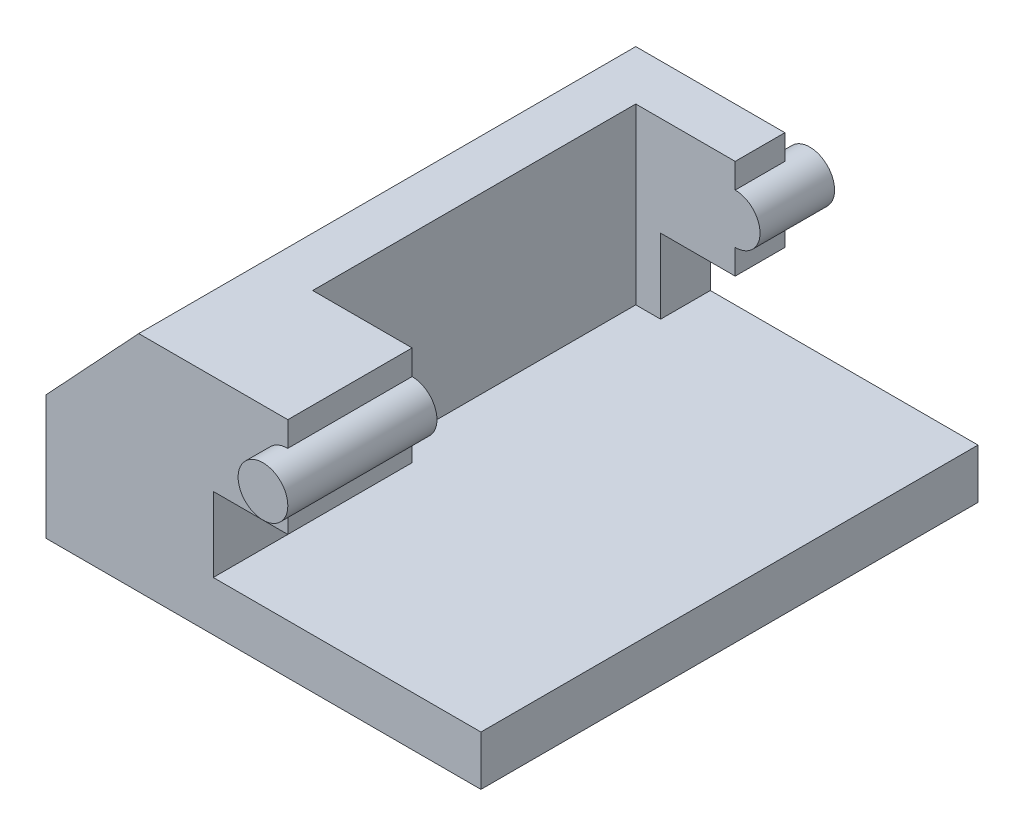
from build123d import *

# Parameters (mm, degrees)
SKETCH3_R               = 5
BOSS_EXTRUDE6_DEPTH     = 50
SKETCH10_R              = 5
BOSS_EXTRUDE7_DEPTH     = 5
SKETCH11_R              = 5
BOSS_EXTRUDE8_DEPTH     = 5
SKETCH13_W              = 58.849698277
SKETCH13_H              = 46.596027217
CUT_EXTRUDE3_DEPTH      = 25
CUT_EXTRUDE3_DEPTH_BACK = 40


with BuildPart() as part:
    # Sketch3 → Boss-Extrude6 (new body, symmetric)
    with BuildSketch(Plane.XY):
        with Locations((-38.849698277, 35)):
            Circle(SKETCH3_R)
        with BuildLine():
            Line((-87.5, 0), (0, 0))
            Line((0, 0), (0, 10))
            Line((0, 10), (-53.849698277, 10))
            Line((-53.849698277, 10), (-53.849698277, 25))
            Line((-53.849698277, 25), (-38.849698277, 25))
            Line((-38.849698277, 25), (-38.849698277, 30))
            ThreePointArc((-38.849698277, 30), (-43.849698277, 35), (-38.849698277, 40))
            Line((-38.849698277, 40), (-38.849698277, 45))
            Line((-38.849698277, 45), (-68.849698277, 45))
            Line((-68.849698277, 45), (-87.5, 25))
            Line((-87.5, 25), (-87.5, 0))
        make_face()
    extrude(amount=BOSS_EXTRUDE6_DEPTH, both=True)

    # Sketch10 → Boss-Extrude7 (add)
    with BuildSketch(Plane.XY.offset(50)):
        with Locations(Location((-38.849698277, 35, 0), (0, 0, 90))):  # turned: the seam where the file's is
            Circle(SKETCH10_R)
    extrude(amount=BOSS_EXTRUDE7_DEPTH)

    # Sketch11 → Boss-Extrude8 (add)
    with BuildSketch(Plane(origin=(0, 0, -50), x_dir=(-1, 0, 0), z_dir=(0, 0, -1))):
        with Locations((38.849698277, 35)):
            Circle(SKETCH11_R)
    extrude(amount=BOSS_EXTRUDE8_DEPTH)

    # Sketch13 → Cut-Extrude3 (cut, two sides)
    with BuildSketch(Plane.XY) as cut_extrude3_sk:
        with Locations((-29.424849139, 33.298013608)):
            Rectangle(SKETCH13_W, SKETCH13_H)
    extrude(amount=CUT_EXTRUDE3_DEPTH, mode=Mode.SUBTRACT)
    extrude(cut_extrude3_sk.sketch, amount=-CUT_EXTRUDE3_DEPTH_BACK, mode=Mode.SUBTRACT)


solid = part.part
